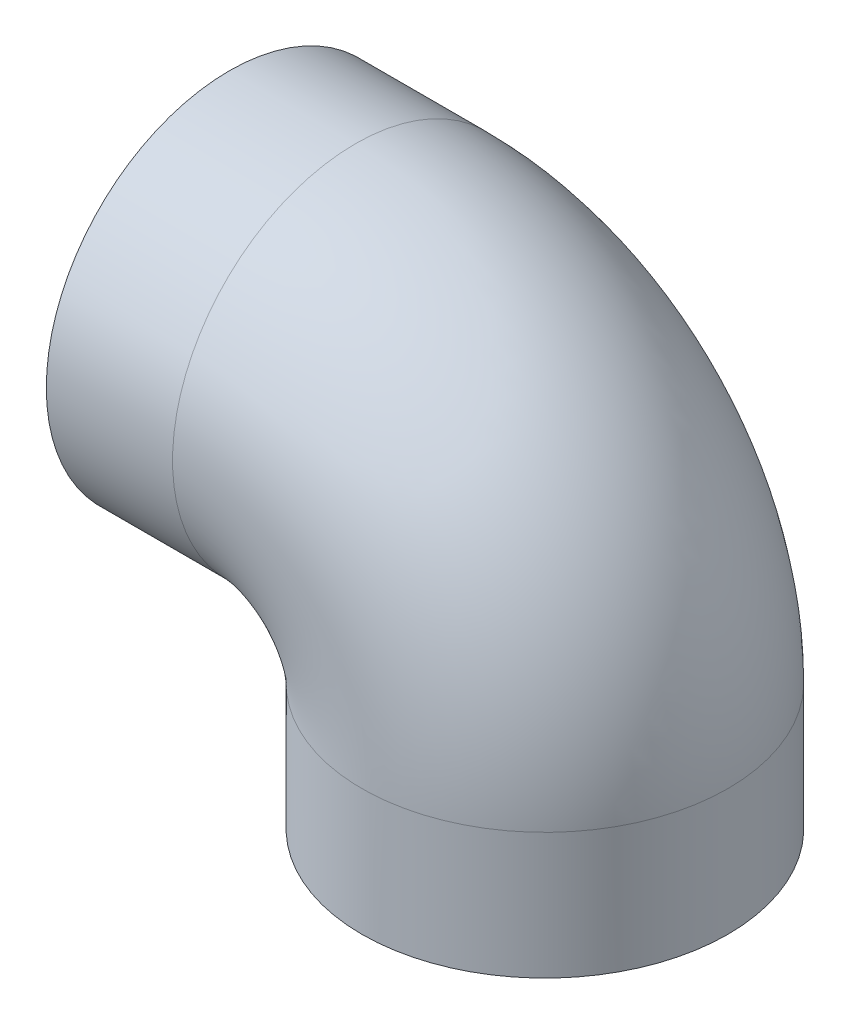
from build123d import *

# Parameters (mm, degrees)
SKETCH2_R          = 29
SKETCH2_R_2        = 25
SKETCH3_R          = 27
SKETCH3_R_2        = 25
CUT_EXTRUDE1_DEPTH = 5
SKETCH4_R          = 27
SKETCH4_R_2        = 25
CUT_EXTRUDE2_DEPTH = 5


with BuildPart() as part:
    # Sweep1: sweep along a path in Sketch1
    with BuildLine(Plane.XY) as sweep1_path:
        Line((-20, 30), (0, 30))
        ThreePointArc((0, 30), (21.213203436, 21.213203436), (30, 0))
        Line((30, 0), (30, -20))
    # Sketch2 → Sweep1 (sweep)
    with BuildSketch(Plane(origin=(0, -20, 0), x_dir=(1, 0, 0), z_dir=(0, 1, 0))):
        with Locations((30, 0)):
            Circle(SKETCH2_R)
        with Locations((30, 0)):
            Circle(SKETCH2_R_2, mode=Mode.SUBTRACT)
    sweep(path=sweep1_path.line)

    # Sketch3 → Cut-Extrude1 (cut)
    with BuildSketch(Plane.ZY.offset(20)):
        with Locations((0, 30)):
            Circle(SKETCH3_R)
        with Locations((0, 30)):
            Circle(SKETCH3_R_2, mode=Mode.SUBTRACT)
    extrude(amount=-CUT_EXTRUDE1_DEPTH, mode=Mode.SUBTRACT)

    # Sketch4 → Cut-Extrude2 (cut)
    with BuildSketch(Plane.XZ.offset(20)):
        with Locations((30, 0)):
            Circle(SKETCH4_R)
        with Locations((30, 0)):
            Circle(SKETCH4_R_2, mode=Mode.SUBTRACT)
    extrude(amount=-CUT_EXTRUDE2_DEPTH, mode=Mode.SUBTRACT)


solid = part.part
